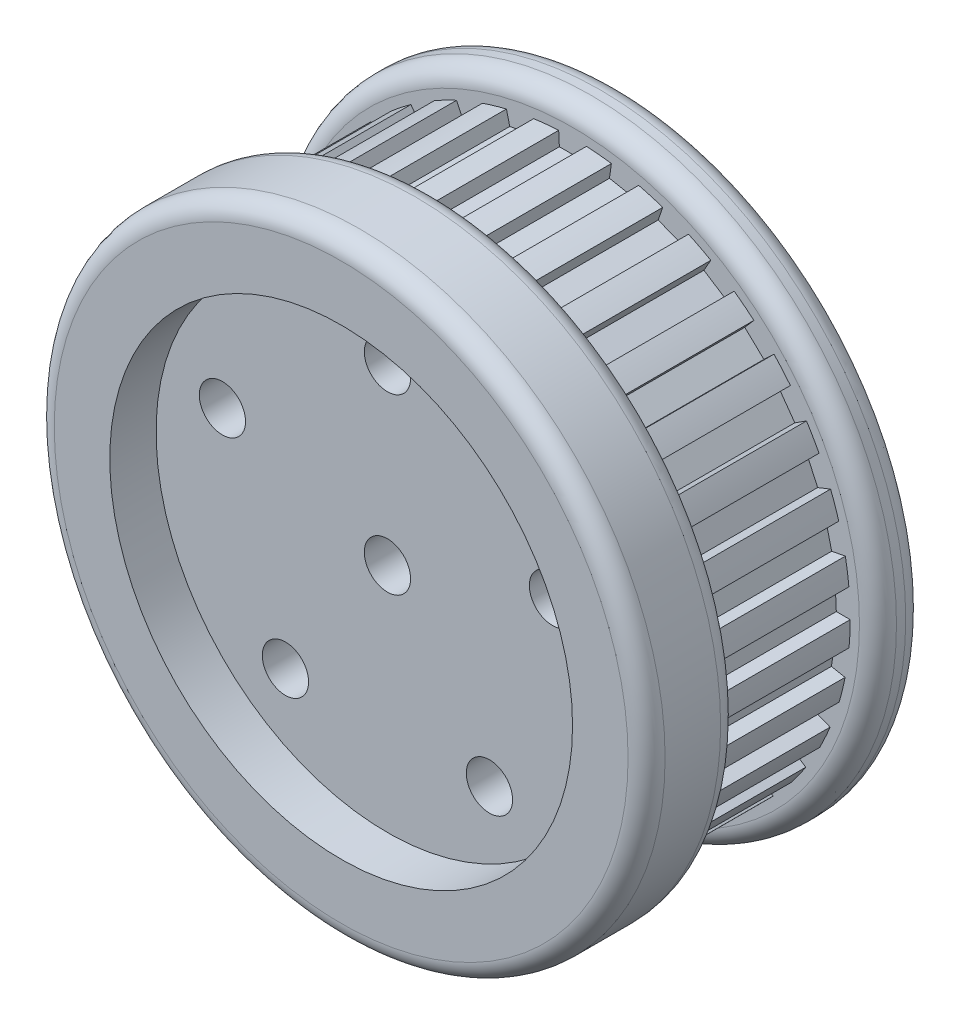
from build123d import *

# Parameters (mm, degrees)
SKETCH2_R               = 2.5
CUT_EXTRUDE2_DEPTH      = 16
CUT_EXTRUDE2_DEPTH_BACK = 16
CUT_EXTRUDE4_DEPTH      = 15
CIRPATTERN1_COUNT       = 33
FILLET1_R               = 2


with BuildPart() as part:
    # Sketch1 → Revolve1 (revolve)
    with BuildSketch(Plane(origin=(0, 0, 0), x_dir=(1, 0, 0), z_dir=(0, 1, 0))):
        Polygon((0, 0), (0, 10), (25, 10), (25, 25), (33, 25), (33, 20), (30, 20), (30, 5), (33, 5), (33, -5), (25, -5), (25, 0), align=None)
    revolve(axis=Axis((0, 0, 0), (0, 0, -1)))

    # Sketch2 → Cut-Extrude2 (cut, two sides)
    with BuildSketch(Plane(origin=(0, 0, -10), x_dir=(-1, 0, 0), z_dir=(0, 0, -1))) as cut_extrude2_sk:
        with Locations((0, 18.75)):
            Circle(SKETCH2_R)
        Circle(SKETCH2_R)
        with Locations((17.832309681, 5.794068645)):
            Circle(SKETCH2_R)
        with Locations((11.02097348, -15.169068645)):
            Circle(SKETCH2_R)
        with Locations((-11.02097348, -15.169068645)):
            Circle(SKETCH2_R)
        with Locations((-17.832309681, 5.794068645)):
            Circle(SKETCH2_R)
    extrude(amount=CUT_EXTRUDE2_DEPTH, mode=Mode.SUBTRACT)
    extrude(cut_extrude2_sk.sketch, amount=-CUT_EXTRUDE2_DEPTH_BACK, mode=Mode.SUBTRACT)

    # Sketch4 → Cut-Extrude4 (cut)
    with BuildSketch(Plane(origin=(0, 0, -5), x_dir=(-1, 0, 0), z_dir=(0, 0, -1))):
        with BuildLine():
            Line((-1.424906074, 28.462476533), (1.424906074, 28.462476533))
            Line((1.424906074, 28.462476533), (1.5, 29.962476533))
            ThreePointArc((1.5, 29.962476533), (0, 30), (-1.5, 29.962476533))
            Line((-1.5, 29.962476533), (-1.424906074, 28.462476533))
        make_face()
    cut_extrude4 = extrude(amount=CUT_EXTRUDE4_DEPTH, mode=Mode.SUBTRACT)

    # CirPattern1: Cut-Extrude4 ×33 about axis
    cirpattern1_axis = Axis((0, 0, 0), (0, 0, 1))
    for i in range(1, CIRPATTERN1_COUNT):
        add(cut_extrude4.rotate(cirpattern1_axis, i * 360 / CIRPATTERN1_COUNT), mode=Mode.SUBTRACT)

    # Fillet1
    fillet1_edges = [part.edges().sort_by_distance(p)[0] for p in [
        (-33, 0, 5),
        (-33, 0, -5),
        (-33, 0, -20),
        (-33, 0, -25),
        (-25, 0, -25),
        (-25, 0, -10),
    ]]
    fillet(fillet1_edges, radius=FILLET1_R)


solid = part.part
